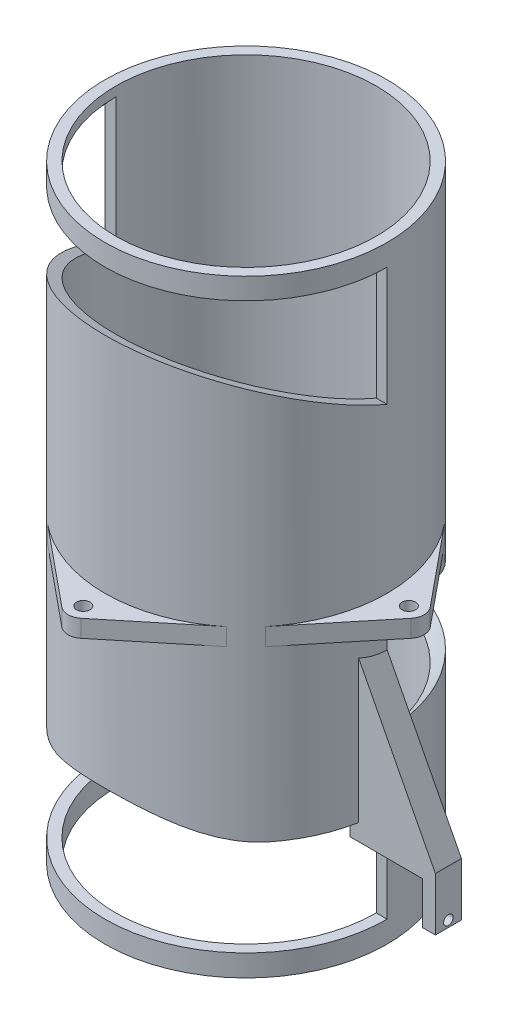
from build123d import *

# Parameters (mm, degrees)
SKETCH1_R               = 32.5
SKETCH1_R_2             = 30
BOSS_EXTRUDE1_DEPTH     = 140
CUT_REVOLVE1_ANGLE      = 67
CUT_REVOLVE2_ANGLE      = 67
CUT_EXTRUDE1_DEPTH      = 58
CUT_EXTRUDE1_DEPTH_BACK = 50
BOSS_EXTRUDE3_START     = -70
SKETCH4_R               = 1.55
BOSS_EXTRUDE3_DEPTH     = 4
SKETCH6_W               = 19.62
SKETCH6_H               = 2.5
BOSS_EXTRUDE4_DEPTH     = 6
SKETCH7_W               = 6
SKETCH7_H               = 9.773229536
BOSS_EXTRUDE6_DEPTH     = 3
SKETCH8_W               = 2.5
SKETCH8_H               = 1.33
BOSS_EXTRUDE7_DEPTH     = 6
SKETCH9_R               = 1.1
CUT_EXTRUDE2_DEPTH      = 7
RIB3_REACH              = 156.088
SKETCH11_WALL_W         = 347.41014935
SKETCH11_WALL_H         = 6


with BuildPart() as part:
    # Sketch1 → Boss-Extrude1 (new body)
    with BuildSketch(Plane(origin=(0, 0, 0), x_dir=(1, 0, 0), z_dir=(0, 1, 0))):
        with Locations(Location((0, 0, 0), (0, 0, 270))):
            Circle(SKETCH1_R)
        with Locations(Location((0, 0, 0), (0, 0, 270))):
            Circle(SKETCH1_R_2, mode=Mode.SUBTRACT)
    extrude(amount=BOSS_EXTRUDE1_DEPTH)

    # Sketch2 → Cut-Revolve1 (revolve, cut)
    with BuildSketch(Plane.XY):
        with BuildLine():
            Line((-42.5, 107.716148379), (42.5, 107.716148379))
            ThreePointArc((42.5, 107.716148379), (0, 150.216148379), (-42.5, 107.716148379))
        make_face()
    revolve(axis=Axis((-42.5, 107.716148379, 0), (1, 0, 0)), revolution_arc=CUT_REVOLVE1_ANGLE, mode=Mode.SUBTRACT)

    # Sketch3 → Cut-Revolve2 (revolve, cut)
    with BuildSketch(Plane.XY):
        with BuildLine():
            Line((-42.5, 70.076349177), (42.5, 70.076349177))
            ThreePointArc((42.5, 70.076349177), (0, 27.576349177), (-42.5, 70.076349177))
        make_face()
    revolve(axis=Axis((-42.5, 70.076349177, 0), (1, 0, 0)), revolution_arc=CUT_REVOLVE2_ANGLE, mode=Mode.SUBTRACT)

    # Sketch5 → Cut-Extrude1 (cut, two sides)
    with BuildSketch(Plane(origin=(0, 0, 0), x_dir=(0, 0, -1), z_dir=(1, 0, 0))) as cut_extrude1_sk:
        with BuildLine():
            Line((-38.488633311, 38.604979811), (-38.087882821, 37.828391715))
            ThreePointArc((-38.087882821, 37.828391715), (-30.720780367, 29.920302027), (-20.314824517, 27))
            Line((-20.314824517, 27), (-19.990167054, 27))
            Line((-19.990167054, 27), (0, 27))
            Line((0, 27), (0, 5))
            Line((0, 5), (-38.488633311, 5))
            Line((-38.488633311, 5), (-38.488633311, 38.604979811))
        make_face()
    extrude(amount=CUT_EXTRUDE1_DEPTH, mode=Mode.SUBTRACT)
    extrude(cut_extrude1_sk.sketch, amount=-CUT_EXTRUDE1_DEPTH_BACK, mode=Mode.SUBTRACT)

    # Sketch4 → Boss-Extrude3 (add)
    with BuildSketch(Plane(origin=(0, 140, 0), x_dir=(1, 0, 0), z_dir=(0, 1, 0)).offset(BOSS_EXTRUDE3_START)):
        with BuildLine():
            Line((-2.218998773, 40.206666667), (-20.604988608, 25.133333333))
            ThreePointArc((-20.604988608, 25.133333333), (0, 32.5), (20.604988608, 25.133333333))
            Line((20.604988608, 25.133333333), (2.218998773, 40.206666667))
            ThreePointArc((2.218998773, 40.206666667), (0, 41), (-2.218998773, 40.206666667))
        make_face()
        with Locations(Location((0, 37.5, 0), (0, 0, 270))):
            Circle(SKETCH4_R, mode=Mode.SUBTRACT)
        with BuildLine():
            ThreePointArc((-25.133333333, -20.604988608), (-32.5, 0), (-25.133333333, 20.604988608))
            Line((-25.133333333, 20.604988608), (-40.206666667, 2.218998773))
            ThreePointArc((-40.206666667, 2.218998773), (-41, 0), (-40.206666667, -2.218998773))
            Line((-40.206666667, -2.218998773), (-25.133333333, -20.604988608))
        make_face()
        with Locations(Location((-37.5, 0, 0), (0, 0, 270))):
            Circle(SKETCH4_R, mode=Mode.SUBTRACT)
        with BuildLine():
            Line((40.206666667, 2.218998773), (25.133333333, 20.604988608))
            ThreePointArc((25.133333333, 20.604988608), (32.5, 0), (25.133333333, -20.604988608))
            Line((25.133333333, -20.604988608), (40.206666667, -2.218998773))
            ThreePointArc((40.206666667, -2.218998773), (41, 0), (40.206666667, 2.218998773))
        make_face()
        with Locations(Location((37.5, 0, 0), (0, 0, 270))):
            Circle(SKETCH4_R, mode=Mode.SUBTRACT)
        with BuildLine():
            ThreePointArc((20.604988608, -25.133333333), (0, -32.5), (-20.604988608, -25.133333333))
            Line((-20.604988608, -25.133333333), (-2.218998773, -40.206666667))
            ThreePointArc((-2.218998773, -40.206666667), (0, -41), (2.218998773, -40.206666667))
            Line((2.218998773, -40.206666667), (20.604988608, -25.133333333))
        make_face()
        with Locations(Location((0, -37.5, 0), (0, 0, 270))):
            Circle(SKETCH4_R, mode=Mode.SUBTRACT)
    extrude(amount=-BOSS_EXTRUDE3_DEPTH)

    # Sketch6 → Boss-Extrude4 (add)
    with BuildSketch(Plane.XY):
        with Locations((39.81, 24.42)):
            Rectangle(SKETCH6_W, SKETCH6_H)
    extrude(amount=BOSS_EXTRUDE4_DEPTH)

    # Sketch7 → Boss-Extrude6 (add)
    with BuildSketch(Plane(origin=(49.62, 0, 0), x_dir=(0, 0, -1), z_dir=(1, 0, 0))):
        with Locations((-3, 18.283385232)):
            Rectangle(SKETCH7_W, SKETCH7_H)
    extrude(amount=-BOSS_EXTRUDE6_DEPTH)

    # Sketch8 → Boss-Extrude7 (add)
    with BuildSketch(Plane.XY):
        Polygon((49.62, 25.67), (32.5, 25.67), (32.5, 27), align=None)
        with Locations((31.25, 26.335)):
            Rectangle(SKETCH8_W, SKETCH8_H)
    extrude(amount=BOSS_EXTRUDE7_DEPTH)

    # Sketch9 → Cut-Extrude2 (cut)
    with BuildSketch(Plane(origin=(49.62, 0, 0), x_dir=(0, 0, -1), z_dir=(1, 0, 0))):
        with Locations((-3, 14.913761398)):
            Circle(SKETCH9_R)
    extrude(amount=-CUT_EXTRUDE2_DEPTH, mode=Mode.SUBTRACT)

    # Sketch11 wall → Rib3 (add, up to next)
    with BuildSketch(Plane(origin=(41.06, 42.202329556, 0), x_dir=(0.459795586238, -0.888024785057, 0), z_dir=(0.888024785057, 0.459795586238, 0)), mode=Mode.PRIVATE) as rib3_sk1:
        with Locations((0, -3)):
            Rectangle(SKETCH11_WALL_W, SKETCH11_WALL_H)
    rib3_tool1 = extrude(rib3_sk1.sketch, amount=-RIB3_REACH, mode=Mode.PRIVATE) - part.part
    add(rib3_tool1.solids().sort_by_distance((41.06, 42.202329556, 0))[0])


solid = part.part
